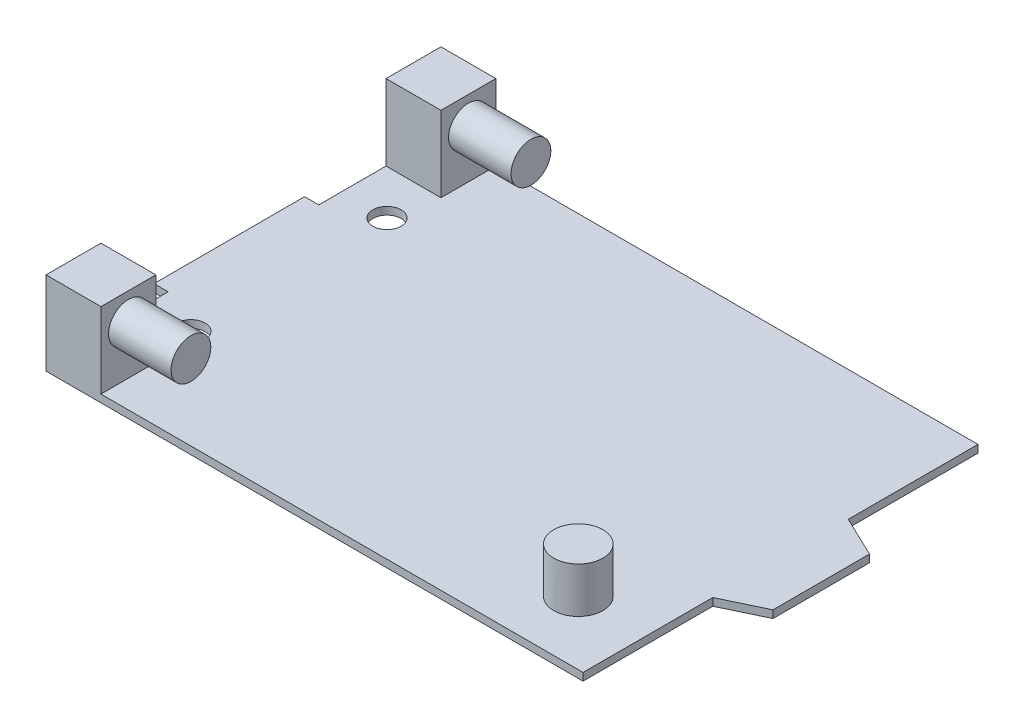
from build123d import *

# Parameters (mm, degrees)
SKETCH1_R           = 1.905
BOSS_EXTRUDE1_DEPTH = 1.016
SKETCH2_W           = 7.366
SKETCH2_H           = 7.366
BOSS_EXTRUDE2_DEPTH = 10.16
SKETCH3_R           = 2.667
BOSS_EXTRUDE3_DEPTH = 8.382
SKETCH4_R           = 3.302
BOSS_EXTRUDE4_DEPTH = 6.096


with BuildPart() as part:
    # Sketch1 → Boss-Extrude1 (new body)
    with BuildSketch(Plane(origin=(0, 0, 0), x_dir=(1, 0, 0), z_dir=(0, 1, 0))):
        Polygon((0, 0), (0, 20.193), (1.905, 20.193), (1.905, 36.576), (73.914, 36.576), (73.914, 19.177), (79.375, 16.5735), (79.375, 3.6195), (73.914, 1.016), (73.914, -16.383), (1.905, -16.383), (1.905, 0), align=None)
        with Locations((8.001, -3.048)):
            Circle(SKETCH1_R, mode=Mode.SUBTRACT)
        with Locations((8.001, 23.241)):
            Circle(SKETCH1_R, mode=Mode.SUBTRACT)
    extrude(amount=BOSS_EXTRUDE1_DEPTH)

    # Sketch2 → Boss-Extrude2 (add)
    with BuildSketch(Plane(origin=(0, 1.016, 0), x_dir=(1, 0, 0), z_dir=(0, 1, 0))):
        with Locations((5.588, 32.893)):
            Rectangle(SKETCH2_W, SKETCH2_H)
        with Locations((5.588, -12.7)):
            Rectangle(SKETCH2_W, SKETCH2_H)
    extrude(amount=BOSS_EXTRUDE2_DEPTH)

    # Sketch3 → Boss-Extrude3 (add)
    with BuildSketch(Plane(origin=(9.271, 0, 0), x_dir=(0, 0, -1), z_dir=(1, 0, 0))):
        with Locations((-12.7, 7.493)):
            Circle(SKETCH3_R)
        with Locations((32.893, 7.493)):
            Circle(SKETCH3_R)
    extrude(amount=BOSS_EXTRUDE3_DEPTH)

    # Sketch4 → Boss-Extrude4 (add)
    with BuildSketch(Plane(origin=(0, 1.016, 0), x_dir=(1, 0, 0), z_dir=(0, 1, 0))):
        with Locations((64.77, -7.874)):
            Circle(SKETCH4_R)
    extrude(amount=BOSS_EXTRUDE4_DEPTH)


solid = part.part
